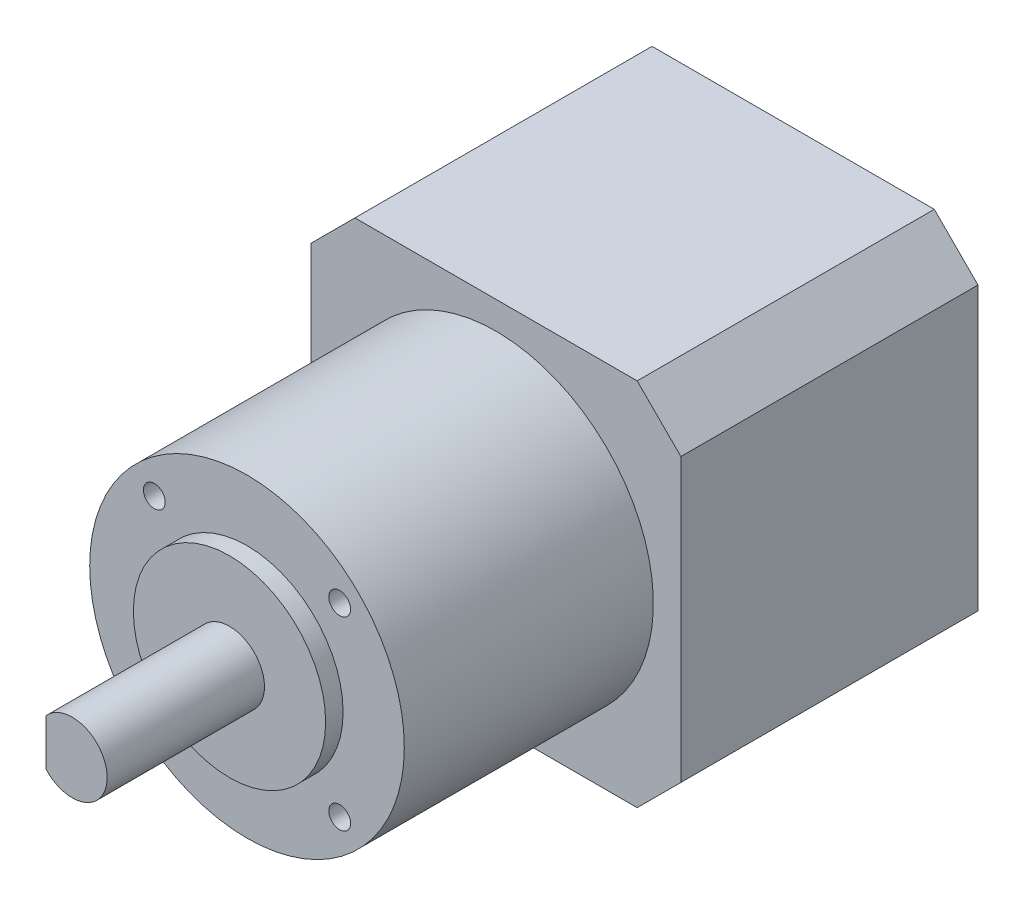
from build123d import *

# Parameters (mm, degrees)
EXTRUDE_1_DEPTH        = 34
SKETCH_2_R             = 18
EXTRUDE_2_DEPTH        = 28.5
SKETCH_3_R             = 11
EXTRUDE_3_DEPTH        = 2
SKETCH_4_R             = 4
EXTRUDE_4_DEPTH        = 18
SKETCH_5_W             = 8.09428643
SKETCH_5_H             = 13.450799509
CUT_EXTRUDE_1_DEPTH    = 15
SKETCH_6_R             = 1
CUT_EXTRUDE_2_DEPTH    = 5
HOLE_WIZARD_M3_1_D     = 2.5
HOLE_WIZARD_M3_1_DEPTH = 7.5
HOLE_WIZARD_M3_1_TIP   = 0.751075774


with BuildPart() as part:
    # 草图1 → 凸台-拉伸1 (new body)
    with BuildSketch(Plane.XY):
        Polygon((-21.15, 16.15), (-16.15, 21.15), (16.15, 21.15), (21.15, 16.15), (21.15, -16.15), (16.15, -21.15), (-16.15, -21.15), (-21.15, -16.15), align=None)
    extrude(amount=EXTRUDE_1_DEPTH)

    # 草图2 → 凸台-拉伸2 (add)
    with BuildSketch(Plane.XY.offset(34)):
        Circle(SKETCH_2_R)
    extrude(amount=EXTRUDE_2_DEPTH)

    # 草图3 → 凸台-拉伸3 (add)
    with BuildSketch(Plane.XY.offset(62.5)):
        Circle(SKETCH_3_R)
    extrude(amount=EXTRUDE_3_DEPTH)

    # 草图4 → 凸台-拉伸4 (add)
    with BuildSketch(Plane.XY.offset(64.5)):
        Circle(SKETCH_4_R)
    extrude(amount=EXTRUDE_4_DEPTH)

    # 草图5 → 切除-拉伸1 (cut)
    with BuildSketch(Plane.XY.offset(82.5)):
        with Locations((-7.047143215, -1.347451383)):
            Rectangle(SKETCH_5_W, SKETCH_5_H)
    extrude(amount=-CUT_EXTRUDE_1_DEPTH, mode=Mode.SUBTRACT)

    # 草图6 → 切除-拉伸2 (cut)
    with BuildSketch(Plane.XY.offset(62.5)):
        with Locations((-10.606601718, 10.606601718)):
            Circle(SKETCH_6_R)
        with Locations((10.606601718, 10.606601718)):
            Circle(SKETCH_6_R)
        with Locations((-10.606601718, -10.606601718)):
            Circle(SKETCH_6_R)
        with Locations((10.606601718, -10.606601718)):
            Circle(SKETCH_6_R)
    extrude(amount=-CUT_EXTRUDE_2_DEPTH, mode=Mode.SUBTRACT)

    # M3 螺纹孔1
    with Locations(Plane.XY.offset(62.5)):
        with Locations((-10.606601718, 10.606601718), (10.606601718, 10.606601718), (-10.606601718, -10.606601718), (10.606601718, -10.606601718)):
            Hole(HOLE_WIZARD_M3_1_D / 2, depth=HOLE_WIZARD_M3_1_DEPTH)
            with Locations((0, 0, -(HOLE_WIZARD_M3_1_DEPTH + HOLE_WIZARD_M3_1_TIP / 2))):  # 118° drill point
                Cone(0, HOLE_WIZARD_M3_1_D / 2, HOLE_WIZARD_M3_1_TIP, mode=Mode.SUBTRACT)


solid = part.part
